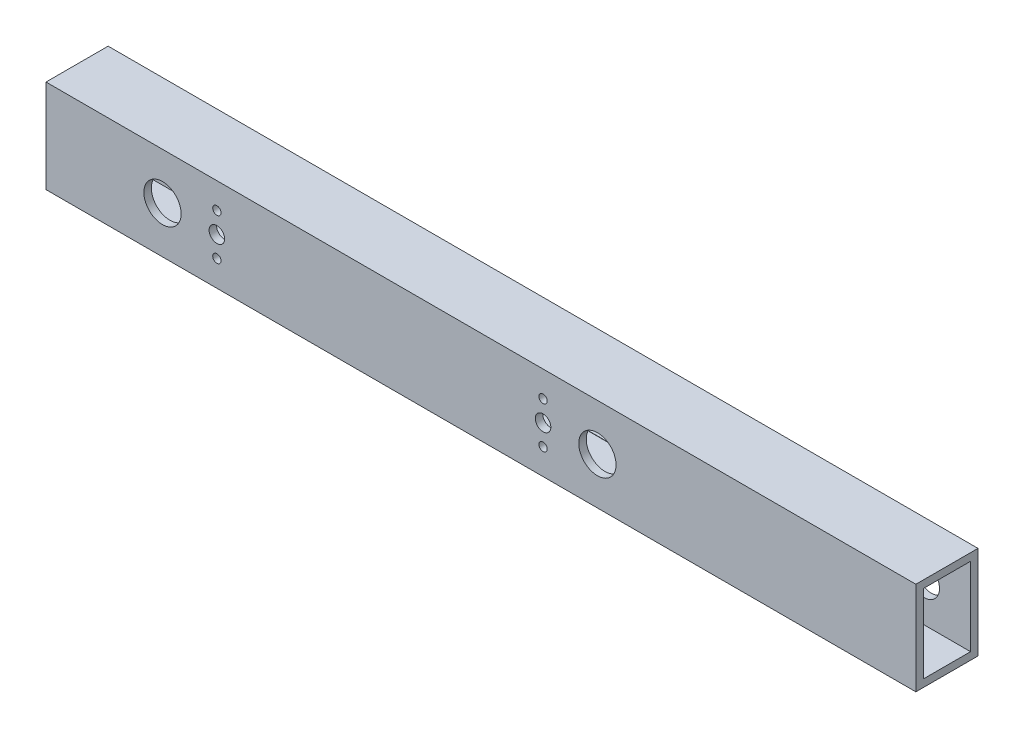
from build123d import *

# Parameters (mm, degrees)
SKETCH1_W                = 25.4
SKETCH1_H                = 38.1
SKETCH1_W_2              = 19.304
SKETCH1_H_2              = 32.004
BOSS_EXTRUDE1_DEPTH      = 355.6
CUT_EXTRUDE1_REACH       = 27.4
SKETCH2_R                = 6.35
CUT_EXTRUDE4_REACH       = 27.4
SKETCH5_R                = 7.62
CUT_EXTRUDE5_REACH       = 27.4
SKETCH6_R                = 3.175
CUT_EXTRUDE6_REACH       = 27.4
M3_CLEARANCE_HOLE1_D     = 3.4
M3_CLEARANCE_HOLE1_DEPTH = 3.048
M3_CLEARANCE_HOLE2_D     = 3.4
M3_CLEARANCE_HOLE2_DEPTH = 3.048


with BuildPart() as part:
    # Sketch1 → Boss-Extrude1 (new body)
    with BuildSketch(Plane(origin=(0, 0, 0), x_dir=(0, 0, -1), z_dir=(1, 0, 0))):
        Rectangle(SKETCH1_W, SKETCH1_H)
        Rectangle(SKETCH1_W_2, SKETCH1_H_2, mode=Mode.SUBTRACT)
    extrude(amount=BOSS_EXTRUDE1_DEPTH)

    # Sketch2 → Cut-Extrude1 (cut, up to next)
    with BuildSketch(Plane(origin=(0, 0, -12.7), x_dir=(-1, 0, 0), z_dir=(0, 0, -1)), mode=Mode.PRIVATE) as cut_extrude1_sk1:
        with Locations((-336.55, 0)):
            Circle(SKETCH2_R)
    cut_extrude1_tool1 = extrude(cut_extrude1_sk1.sketch, amount=-CUT_EXTRUDE1_REACH, mode=Mode.PRIVATE) & part.part
    add(cut_extrude1_tool1.solids().sort_by_distance((336.55, 0, -12.7))[0], mode=Mode.SUBTRACT)

    # Sketch5 → Cut-Extrude4 (cut, up to next)
    with BuildSketch(Plane.XY.offset(12.7), mode=Mode.PRIVATE) as cut_extrude4_sk1:
        with Locations((47.625, 0)):
            Circle(SKETCH5_R)
    cut_extrude4_tool1 = extrude(cut_extrude4_sk1.sketch, amount=-CUT_EXTRUDE4_REACH, mode=Mode.PRIVATE) & part.part
    add(cut_extrude4_tool1.solids().sort_by_distance((47.625, 0, 12.7))[0], mode=Mode.SUBTRACT)
    # Sketch5 → Cut-Extrude4 (cut, up to next)
    with BuildSketch(Plane.XY.offset(12.7), mode=Mode.PRIVATE) as cut_extrude4_sk2:
        with Locations((225.425, 0)):
            Circle(SKETCH5_R)
    cut_extrude4_tool2 = extrude(cut_extrude4_sk2.sketch, amount=-CUT_EXTRUDE4_REACH, mode=Mode.PRIVATE) & part.part
    add(cut_extrude4_tool2.solids().sort_by_distance((225.425, 0, 12.7))[0], mode=Mode.SUBTRACT)

    # Sketch6 → Cut-Extrude5 (cut, up to next)
    with BuildSketch(Plane.XY.offset(12.7), mode=Mode.PRIVATE) as cut_extrude5_sk1:
        with Locations((69.85, 0)):
            Circle(SKETCH6_R)
    cut_extrude5_tool1 = extrude(cut_extrude5_sk1.sketch, amount=-CUT_EXTRUDE5_REACH, mode=Mode.PRIVATE) & part.part
    add(cut_extrude5_tool1.solids().sort_by_distance((69.85, 0, 12.7))[0], mode=Mode.SUBTRACT)
    # Sketch6 → Cut-Extrude5 (cut, up to next)
    with BuildSketch(Plane.XY.offset(12.7), mode=Mode.PRIVATE) as cut_extrude5_sk2:
        with Locations((203.2, 0)):
            Circle(SKETCH6_R)
    cut_extrude5_tool2 = extrude(cut_extrude5_sk2.sketch, amount=-CUT_EXTRUDE5_REACH, mode=Mode.PRIVATE) & part.part
    add(cut_extrude5_tool2.solids().sort_by_distance((203.2, 0, 12.7))[0], mode=Mode.SUBTRACT)

    # Sketch7 → Cut-Extrude6 (cut, up to next)
    with BuildSketch(Plane(origin=(0, 0, -12.7), x_dir=(-1, 0, 0), z_dir=(0, 0, -1)), mode=Mode.PRIVATE) as cut_extrude6_sk1:
        with BuildLine():
            Line((-242.8875, -15.875), (-185.7375, -15.875))
            ThreePointArc((-185.7375, -15.875), (-183.49243597, -14.94506403), (-182.5625, -12.7))
            Line((-182.5625, -12.7), (-182.5625, 12.7))
            ThreePointArc((-182.5625, 12.7), (-183.49243597, 14.94506403), (-185.7375, 15.875))
            Line((-185.7375, 15.875), (-242.8875, 15.875))
            ThreePointArc((-242.8875, 15.875), (-245.13256403, 14.94506403), (-246.0625, 12.7))
            Line((-246.0625, 12.7), (-246.0625, -12.7))
            ThreePointArc((-246.0625, -12.7), (-245.13256403, -14.94506403), (-242.8875, -15.875))
        make_face()
    cut_extrude6_tool1 = extrude(cut_extrude6_sk1.sketch, amount=-CUT_EXTRUDE6_REACH, mode=Mode.PRIVATE) & part.part
    add(cut_extrude6_tool1.solids().sort_by_distance((214.3125, 0, -12.7))[0], mode=Mode.SUBTRACT)
    # Sketch7 → Cut-Extrude6 (cut, up to next)
    with BuildSketch(Plane(origin=(0, 0, -12.7), x_dir=(-1, 0, 0), z_dir=(0, 0, -1)), mode=Mode.PRIVATE) as cut_extrude6_sk2:
        with BuildLine():
            Line((-87.3125, -15.875), (-30.1625, -15.875))
            ThreePointArc((-30.1625, -15.875), (-27.91743597, -14.94506403), (-26.9875, -12.7))
            Line((-26.9875, -12.7), (-26.9875, 12.7))
            ThreePointArc((-26.9875, 12.7), (-27.91743597, 14.94506403), (-30.1625, 15.875))
            Line((-30.1625, 15.875), (-87.3125, 15.875))
            ThreePointArc((-87.3125, 15.875), (-89.55756403, 14.94506403), (-90.4875, 12.7))
            Line((-90.4875, 12.7), (-90.4875, -12.7))
            ThreePointArc((-90.4875, -12.7), (-89.55756403, -14.94506403), (-87.3125, -15.875))
        make_face()
    cut_extrude6_tool2 = extrude(cut_extrude6_sk2.sketch, amount=-CUT_EXTRUDE6_REACH, mode=Mode.PRIVATE) & part.part
    add(cut_extrude6_tool2.solids().sort_by_distance((58.7375, 0, -12.7))[0], mode=Mode.SUBTRACT)

    # M3 Clearance Hole1
    with Locations(Plane(origin=(165.1, 3.175, -12.7), x_dir=(-1, 0, 0), z_dir=(0, 0, -1))):
        with Locations((0, 0), (57.15, 0)):
            Hole(M3_CLEARANCE_HOLE1_D / 2, depth=M3_CLEARANCE_HOLE1_DEPTH)

    # M3 Clearance Hole2
    with Locations(Plane(origin=(69.85, 8.5, 12.7), x_dir=(1, 0, 0), z_dir=(0, 0, 1))):
        with Locations((0, 0), (0, -17), (133.35, 0), (133.35, -17)):
            Hole(M3_CLEARANCE_HOLE2_D / 2, depth=M3_CLEARANCE_HOLE2_DEPTH)


solid = part.part
